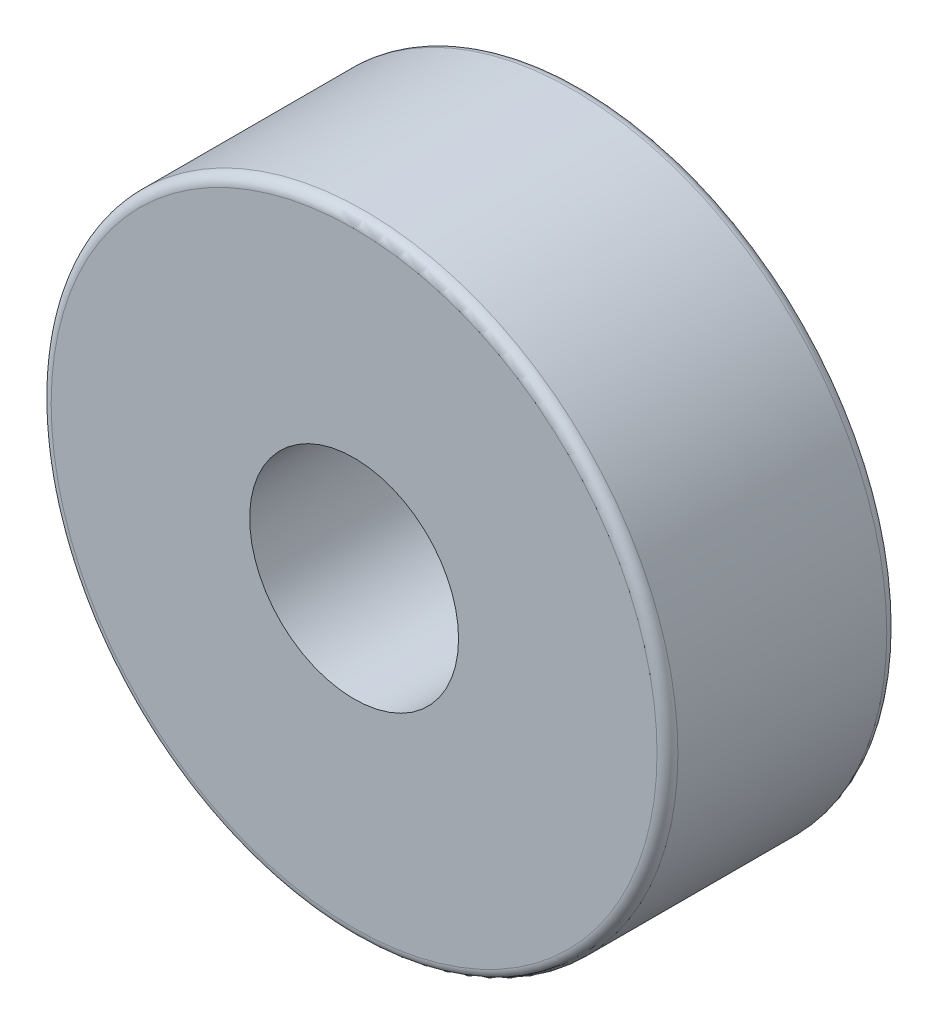
from build123d import *

# Parameters (mm, degrees)
SKETCH1_R           = 30
BOSS_EXTRUDE1_DEPTH = 22
SKETCH2_R           = 10
CUT_EXTRUDE1_DEPTH  = 66
FILLET1_R           = 1
CUT_EXTRUDE2_DEPTH  = 2


with BuildPart() as part:
    # Sketch1 → Boss-Extrude1 (new body)
    with BuildSketch(Plane.XY):
        Circle(SKETCH1_R)
    extrude(amount=BOSS_EXTRUDE1_DEPTH)

    # Sketch2 → Cut-Extrude1 (cut)
    with BuildSketch(Plane(origin=(0, 0, 0), x_dir=(-1, 0, 0), z_dir=(0, 0, -1))):
        Circle(SKETCH2_R)
    extrude(amount=-CUT_EXTRUDE1_DEPTH, mode=Mode.SUBTRACT)

    # Fillet1
    fillet1_edges = [part.edges().sort_by_distance(p)[0] for p in [
        (-30, 0, 0),
        (-30, 0, 22),
    ]]
    fillet(fillet1_edges, radius=FILLET1_R)

    # Sketch3 → Cut-Extrude2 (cut)
    with BuildSketch(Plane(origin=(0, 0, 0), x_dir=(-1, 0, 0), z_dir=(0, 0, -1))):
        with BuildLine():
            Line((-0.5, 24.9949995), (-0.5, 3.464101615))
            ThreePointArc((-0.5, 3.464101615), (-2.474873734, 2.474873734), (-3.464101615, 0.5))
            Line((-3.464101615, 0.5), (-24.9949995, 0.5))
            ThreePointArc((-24.9949995, 0.5), (-17.67766953, 17.67766953), (-0.5, 24.9949995))
        make_face()
        with BuildLine():
            Line((0.5, 24.9949995), (0.5, 3.464101615))
            ThreePointArc((0.5, 3.464101615), (2.474873734, 2.474873734), (3.464101615, 0.5))
            Line((3.464101615, 0.5), (24.9949995, 0.5))
            ThreePointArc((24.9949995, 0.5), (17.67766953, 17.67766953), (0.5, 24.9949995))
        make_face()
        with BuildLine():
            Line((-24.9949995, -0.5), (-3.464101615, -0.5))
            ThreePointArc((-3.464101615, -0.5), (-2.474873734, -2.474873734), (-0.5, -3.464101615))
            Line((-0.5, -3.464101615), (-0.5, -24.9949995))
            ThreePointArc((-0.5, -24.9949995), (-17.67766953, -17.67766953), (-24.9949995, -0.5))
        make_face()
        with BuildLine():
            Line((0.5, -3.464101615), (0.5, -24.9949995))
            ThreePointArc((0.5, -24.9949995), (17.67766953, -17.67766953), (24.9949995, -0.5))
            Line((24.9949995, -0.5), (3.464101615, -0.5))
            ThreePointArc((3.464101615, -0.5), (2.474873734, -2.474873734), (0.5, -3.464101615))
        make_face()
    extrude(amount=-CUT_EXTRUDE2_DEPTH, mode=Mode.SUBTRACT)


solid = part.part
